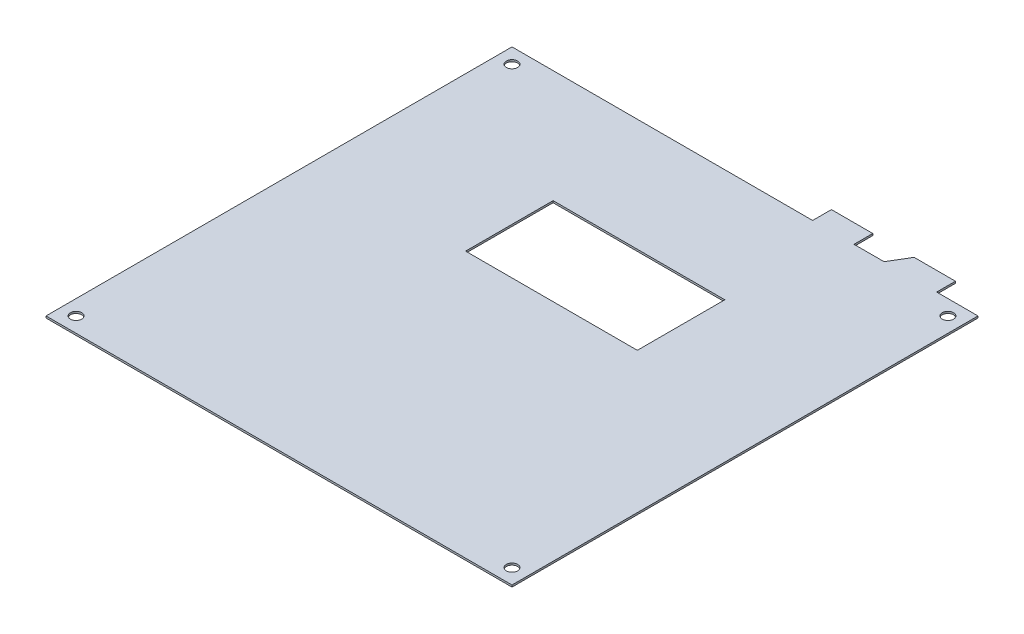
from build123d import *

# Parameters (mm, degrees)
SKETCH_2_W      = 45.704303388
SKETCH_2_H      = 23.283324367
SKETCH_2_R      = 1.5
EXTRUDE_1_DEPTH = 0.5


with BuildPart() as part:
    # Эскиз2 → Бобышка-Вытянуть1 (new body)
    with BuildSketch(Plane(origin=(0, 0, 0), x_dir=(1, 0, 0), z_dir=(0, 1, 0))):
        Polygon((113, 129), (102, 129), (99, 124), (91, 124), (91, 129), (80, 129), (80, 124), (0, 124), (0, 0), (124, 0), (124, 124), (113, 124), align=None)
        with Locations((63.748070218, 82.395863996)):
            Rectangle(SKETCH_2_W, SKETCH_2_H, mode=Mode.SUBTRACT)
        with Locations((120, 120)):
            Circle(SKETCH_2_R, mode=Mode.SUBTRACT)
        with Locations((4, 4)):
            Circle(SKETCH_2_R, mode=Mode.SUBTRACT)
        with Locations((120, 4)):
            Circle(SKETCH_2_R, mode=Mode.SUBTRACT)
        with Locations((4, 120)):
            Circle(SKETCH_2_R, mode=Mode.SUBTRACT)
    extrude(amount=EXTRUDE_1_DEPTH)


solid = part.part
